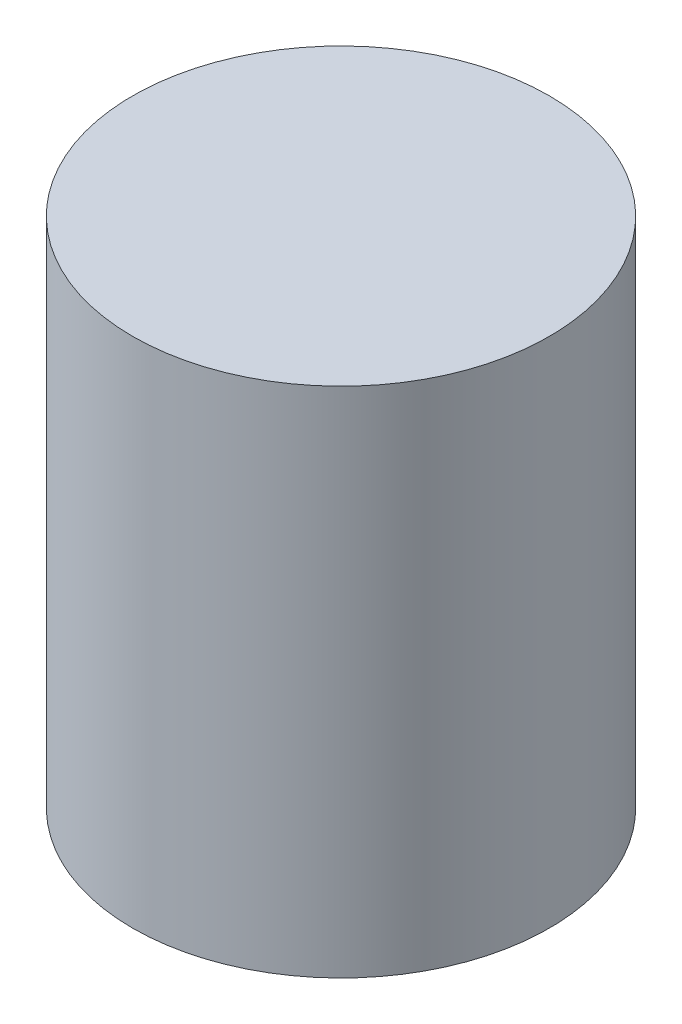
from build123d import *

# Parameters (mm, degrees)
SKETCH_1_R      = 20.32727185
EXTRUDE_3_DEPTH = 50


with BuildPart() as part:
    # 草图1 → 凸台-拉伸3 (new body)
    with BuildSketch(Plane(origin=(0, 0, 0), x_dir=(1, 0, 0), z_dir=(0, 1, 0))):
        with Locations((-8.111037495, 1.669919484)):
            Circle(SKETCH_1_R)
    extrude(amount=EXTRUDE_3_DEPTH)


solid = part.part
